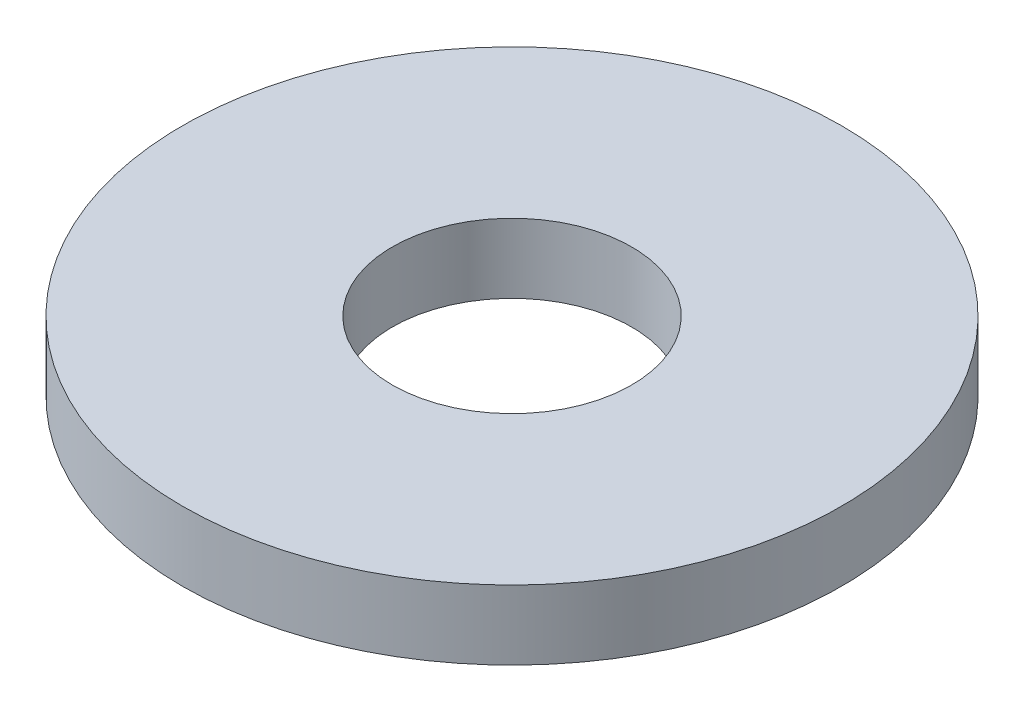
from build123d import *

# Parameters (mm, degrees)
ESQUISSE1_R        = 9.5
ESQUISSE1_R_2      = 3.45
BOSS_EXTRU_1_DEPTH = 2


with BuildPart() as part:
    # Esquisse1 → Boss.-Extru.1 (new body)
    with BuildSketch(Plane(origin=(0, 0, 0), x_dir=(1, 0, 0), z_dir=(0, 1, 0))):
        Circle(ESQUISSE1_R)
        Circle(ESQUISSE1_R_2, mode=Mode.SUBTRACT)
    extrude(amount=BOSS_EXTRU_1_DEPTH)


solid = part.part
